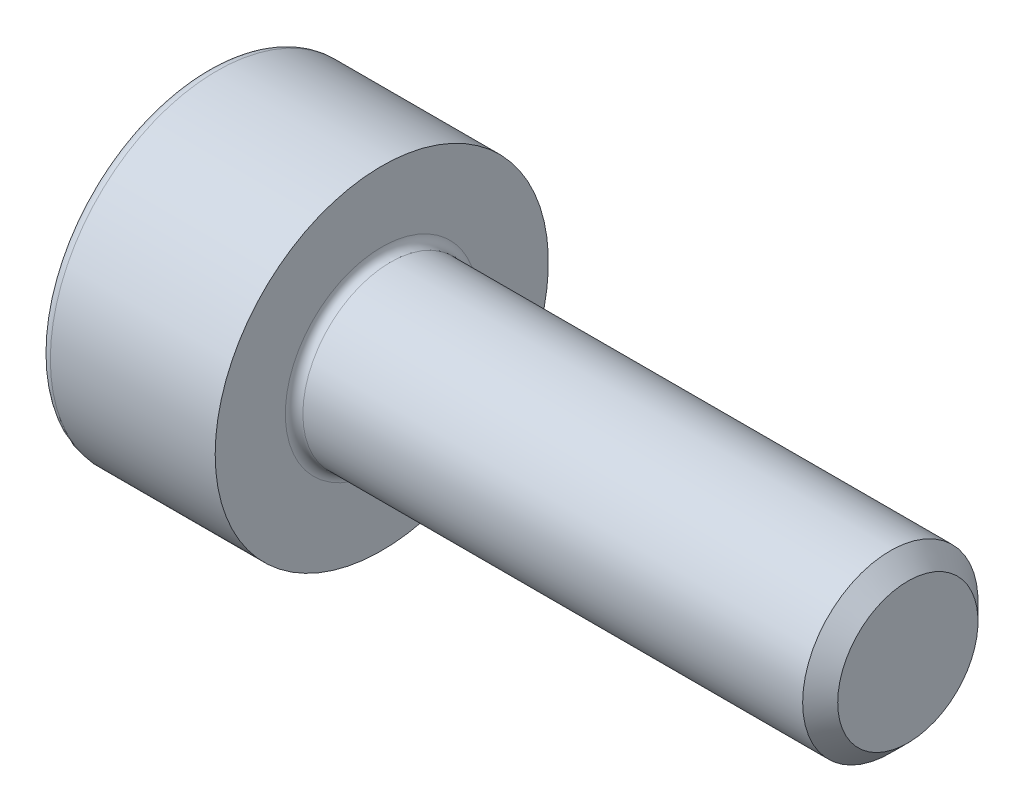
from build123d import *

# Parameters (mm, degrees)
FILLET1_R      = 0.1
FILLET2_R      = 0.12
CHAMFER1_SIZE  = 0.2
EXTRUDE1_DEPTH = 1


with BuildPart() as part:
    # Sketch1 → Revolve1 (revolve)
    with BuildSketch(Plane.XY, mode=Mode.PRIVATE) as revolve1_sk:
        Polygon((2, 1), (2, 0), (4.279914881, 0), (8, 0), (8, 1), align=None)
        Polygon((0, 1.9), (0, 0), (2, 0), (2, 1), (2, 1.9), align=None)
    revolve(revolve1_sk.sketch.rotate(Axis((0, 0, 0), (1, 0, 0)), 90), axis=Axis((0, 0, 0), (1, 0, 0)))

    # Fillet1
    fillet1_edges = [part.edges().sort_by_distance(p)[0] for p in [
        (2, 0, -1),
    ]]
    fillet(fillet1_edges, radius=FILLET1_R)

    # Fillet2
    fillet2_edges = [part.edges().sort_by_distance(p)[0] for p in [
        (0, 0, -1.9),
    ]]
    fillet(fillet2_edges, radius=FILLET2_R)

    # Chamfer1
    chamfer1_edges = [part.edges().sort_by_distance(p)[0] for p in [
        (8, 0, -1),
    ]]
    chamfer(chamfer1_edges, length=CHAMFER1_SIZE)

    # Sketch2 → Extrude1 (cut)
    with BuildSketch(Plane.ZY):
        Polygon((0, 0.866025404), (-0.75, 0.433012702), (-0.75, -0.433012702), (0, -0.866025404), (0.75, -0.433012702), (0.75, 0.433012702), align=None)
    extrude(amount=-EXTRUDE1_DEPTH, mode=Mode.SUBTRACT)


solid = part.part
